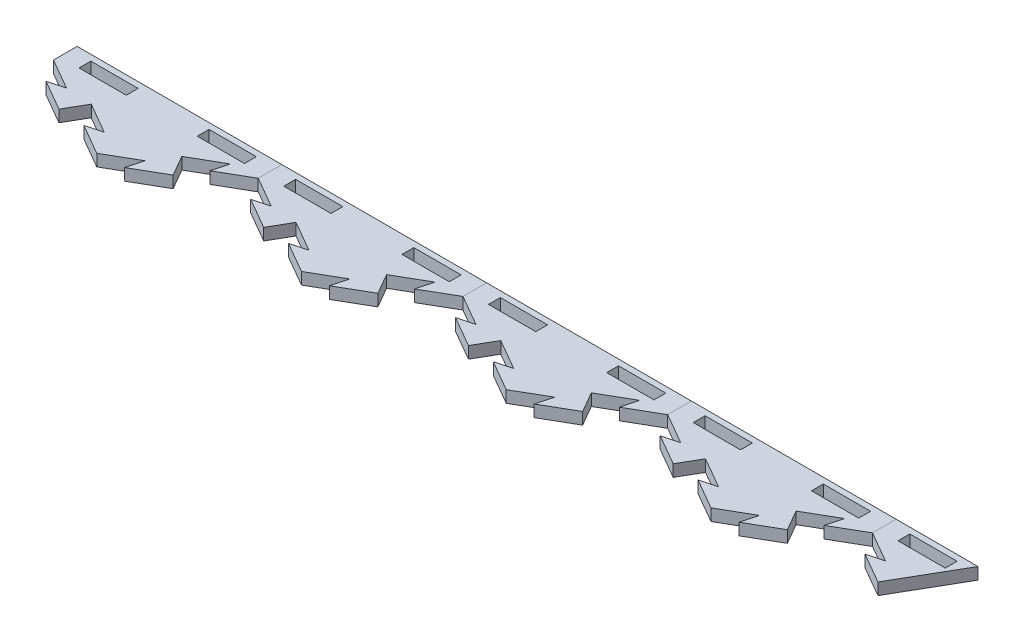
from build123d import *

# Parameters (mm, degrees)
BOSS_EXTRUDE1_DEPTH = 6.35
CUT_EXTRUDE4_DEPTH  = 111.168382488
BOSS_EXTRUDE4_DEPTH = 6.35
CIRPATTERN1_COUNT   = 2
CIRPATTERN1_ANGLE   = 60
SKETCH12_W          = 109.98522628
SKETCH12_H          = 82.55
CUT_EXTRUDE5_DEPTH  = 111.168382488
SKETCH13_W          = 25.4
SKETCH13_H          = 6.35
CUT_EXTRUDE6_DEPTH  = 64.816710194
LPATTERN1_COUNT     = 5
LPATTERN1_PITCH     = 109.985226308
LPATTERN1_2_COUNT   = 2
LPATTERN1_2_PITCH   = 109.985226308
SKETCH14_W          = 25.4
SKETCH14_H          = 6.35
CUT_EXTRUDE7_DEPTH  = 496.991504573
SKETCH15_W          = 43.994090512
SKETCH15_H          = 23.075738686
CUT_EXTRUDE8_DEPTH  = 431.162704792


with BuildPart() as part:
    # Sketch1 → Boss-Extrude1 (new body)
    with BuildSketch(Plane(origin=(0, 0, 0), x_dir=(1, 0, 0), z_dir=(0, 1, 0))):
        Polygon((-54.99261314, 0), (0, -31.75), (54.99261314, 0), (54.99261314, 63.5), (0, 95.25), (-54.99261314, 63.5), align=None)
    extrude(amount=-BOSS_EXTRUDE1_DEPTH)

    # Sketch10 → Cut-Extrude4 (cut, through all)
    with BuildSketch(Plane(origin=(0, 0, 0), x_dir=(1, 0, 0), z_dir=(0, 1, 0))):
        Polygon((-16.497783942, -22.225), (-7.823522628, -19.900738686), (-24.32130657, -10.375738686), (-27.49630657, -15.875), align=None)
    cut_extrude4 = extrude(amount=-CUT_EXTRUDE4_DEPTH, mode=Mode.SUBTRACT)

    # Sketch11 → Boss-Extrude4 (add)
    with BuildSketch(Plane(origin=(0, 0, 0), x_dir=(1, 0, 0), z_dir=(0, 1, 0))):
        Polygon((-27.49630657, -15.875), (-30.67130657, -21.374261314), (-47.169090512, -11.849261314), (-38.494829198, -9.525), align=None)
    boss_extrude4 = extrude(amount=-BOSS_EXTRUDE4_DEPTH)

    # CirPattern1: Cut-Extrude4, Boss-Extrude4 ×2 about axis
    cirpattern1_axis = Axis((0, 0, -31.75), (0, 1, 0))
    add([cut_extrude4.rotate(cirpattern1_axis, i * CIRPATTERN1_ANGLE / (CIRPATTERN1_COUNT - 1)) for i in range(1, CIRPATTERN1_COUNT)], mode=Mode.SUBTRACT)
    add([boss_extrude4.rotate(cirpattern1_axis, i * CIRPATTERN1_ANGLE / (CIRPATTERN1_COUNT - 1)) for i in range(1, CIRPATTERN1_COUNT)])

    # Sketch12 → Cut-Extrude5 (cut, through all)
    with BuildSketch(Plane(origin=(0, 0, 0), x_dir=(1, 0, 0), z_dir=(0, 1, 0))):
        with Locations((0, 53.975)):
            Rectangle(SKETCH12_W, SKETCH12_H)
    extrude(amount=-CUT_EXTRUDE5_DEPTH, mode=Mode.SUBTRACT)

    # Sketch13 → Cut-Extrude6 (cut, through all)
    with BuildSketch(Plane(origin=(0, 0, 0), x_dir=(1, 0, 0), z_dir=(0, 1, 0))):
        with Locations((-31.75, 6.35)):
            Rectangle(SKETCH13_W, SKETCH13_H)
        with Locations((31.75, 6.35)):
            Rectangle(SKETCH13_W, SKETCH13_H)
    extrude(amount=-CUT_EXTRUDE6_DEPTH, mode=Mode.SUBTRACT)


with BuildPart() as lpattern1_1:
    # LPattern1: pattern copy
    add(part.part.moved(Location(Vector(1, 0, 0) * (1 * LPATTERN1_PITCH))))


with BuildPart() as lpattern1_2:
    # LPattern1: pattern copy
    add(part.part.moved(Location(Vector(1, 0, 0) * (2 * LPATTERN1_PITCH))))


with BuildPart() as lpattern1_3:
    # LPattern1: pattern copy
    add(part.part.moved(Location(Vector(1, 0, 0) * (3 * LPATTERN1_PITCH))))


with BuildPart() as lpattern1_4:
    # LPattern1: pattern copy
    add(part.part.moved(Location(Vector(1, 0, 0) * (4 * LPATTERN1_PITCH))))


with BuildPart() as lpattern1_2_1:
    # LPattern1 2: pattern copy
    add(part.part.moved(Location(Vector(-1, 0, 0) * (1 * LPATTERN1_2_PITCH))))


with BuildPart() as cut_extrude7_tool:
    # Sketch14 → Cut-Extrude7 (new, through all)
    # profile 1 of 2: a face of its own
    with BuildSketch(Plane(origin=(0, 0, 0), x_dir=(1, 0, 0), z_dir=(0, 1, 0))):
        Polygon((423.44312129, -22.225), (439.940905232, -31.75), (456.438689174, -22.225), (454.11442786, -30.899261314), (470.612211802, -21.374261314), (464.262211802, -10.375738686), (480.759995744, -0.850738686), (478.43573443, -9.525), (494.933518372, 0), (494.933518372, 12.7), (428.942382604, 12.7), (415.619598662, -10.375738686), (432.117382604, -19.900738686), align=None)
        with Locations((471.690905232, 6.35)):
            Rectangle(SKETCH14_W, SKETCH14_H, mode=Mode.SUBTRACT)
    # profile 2 of 2: a face of its own
    with BuildSketch(Plane(origin=(0, 0, 0), x_dir=(1, 0, 0), z_dir=(0, 1, 0))):
        Polygon((-164.977839448, -31.75), (-109.985226308, -31.75), (-95.81170368, -30.899261314), (-79.313919738, -21.374261314), (-98.98670368, 12.7), (-164.977839448, 12.7), align=None)
    extrude(amount=-CUT_EXTRUDE7_DEPTH)


with BuildPart() as lpattern1_4_1:
    add(lpattern1_4.part)

    # Cut-Extrude7: cut by cut_extrude7_tool
    add(cut_extrude7_tool.part, mode=Mode.SUBTRACT)


with BuildPart() as lpattern1_2_1_1:
    add(lpattern1_2_1.part)

    # Cut-Extrude7: cut by cut_extrude7_tool
    add(cut_extrude7_tool.part, mode=Mode.SUBTRACT)

    # Sketch15 → Cut-Extrude8 (cut, through all)
    with BuildSketch(Plane(origin=(0, 0, 0), x_dir=(1, 0, 0), z_dir=(0, 1, 0))):
        with Locations((-76.989658424, 1.162130657)):
            Rectangle(SKETCH15_W, SKETCH15_H)
    extrude(amount=-CUT_EXTRUDE8_DEPTH, mode=Mode.SUBTRACT)


solid = Compound([part.part, lpattern1_1.part, lpattern1_2.part, lpattern1_3.part, lpattern1_4_1.part])
